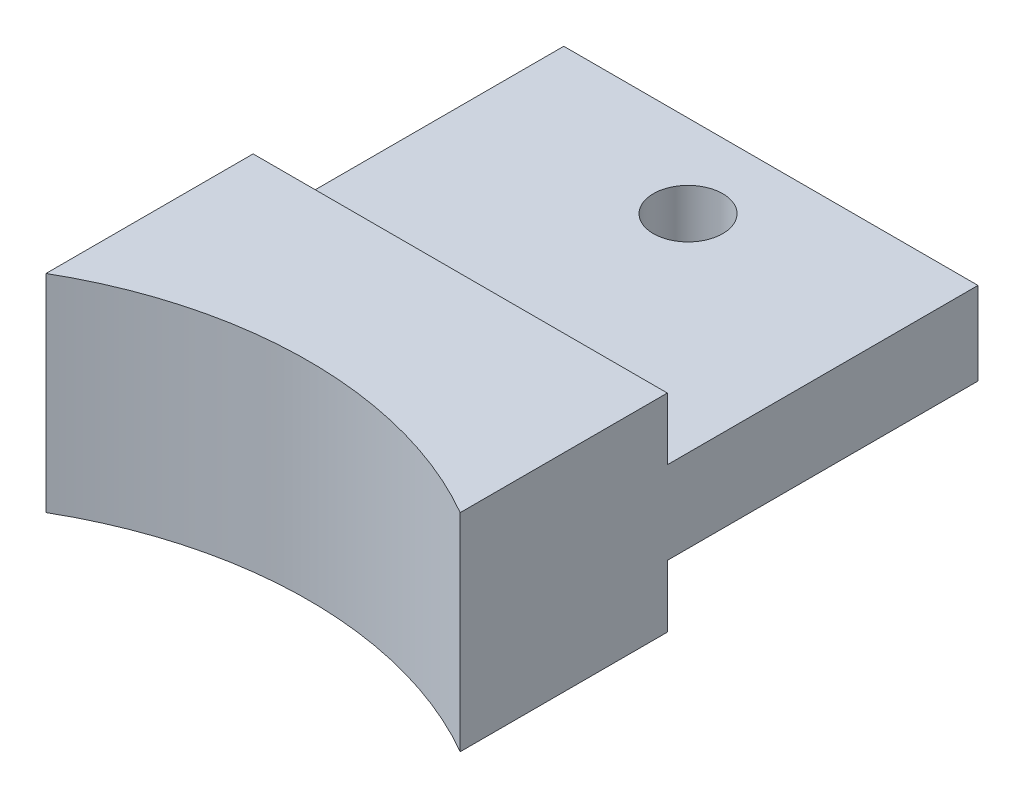
from build123d import *

# Parameters (mm, degrees)
SKETCH1_W                       = 20
SKETCH1_H                       = 10
BOSS_EXTRUDE1_DEPTH             = 10
CUT_EXTRUDE1_DEPTH              = 10
SKETCH3_W                       = 20
SKETCH3_H                       = 4
BOSS_EXTRUDE2_DEPTH             = 15
TAP_DRILL_FOR_M3X0_5_TAP6_D     = 3.35
TAP_DRILL_FOR_M3X0_5_TAP6_DEPTH = 4


with BuildPart() as part:
    # Sketch1 → Boss-Extrude1 (new body)
    with BuildSketch(Plane.XY):
        Rectangle(SKETCH1_W, SKETCH1_H)
    extrude(amount=BOSS_EXTRUDE1_DEPTH)

    # Sketch2 → Cut-Extrude1 (cut)
    with BuildSketch(Plane(origin=(0, 5, 0), x_dir=(1, 0, 0), z_dir=(0, 1, 0))):
        with BuildLine():
            Line((-10, -10), (10, -10))
            ThreePointArc((10, -10), (0, -7.320508076), (-10, -10))
        make_face()
    extrude(amount=-CUT_EXTRUDE1_DEPTH, mode=Mode.SUBTRACT)

    # Sketch3 → Boss-Extrude2 (add)
    with BuildSketch(Plane(origin=(0, 0, 0), x_dir=(-1, 0, 0), z_dir=(0, 0, -1))):
        Rectangle(SKETCH3_W, SKETCH3_H)
    extrude(amount=BOSS_EXTRUDE2_DEPTH)

    # Tap Drill for M3x0.5 Tap6
    with Locations(Plane(origin=(0, 2, 0), x_dir=(1, 0, 0), z_dir=(0, 1, 0))):
        with Locations((0, 11)):
            Hole(TAP_DRILL_FOR_M3X0_5_TAP6_D / 2, depth=TAP_DRILL_FOR_M3X0_5_TAP6_DEPTH)


solid = part.part
